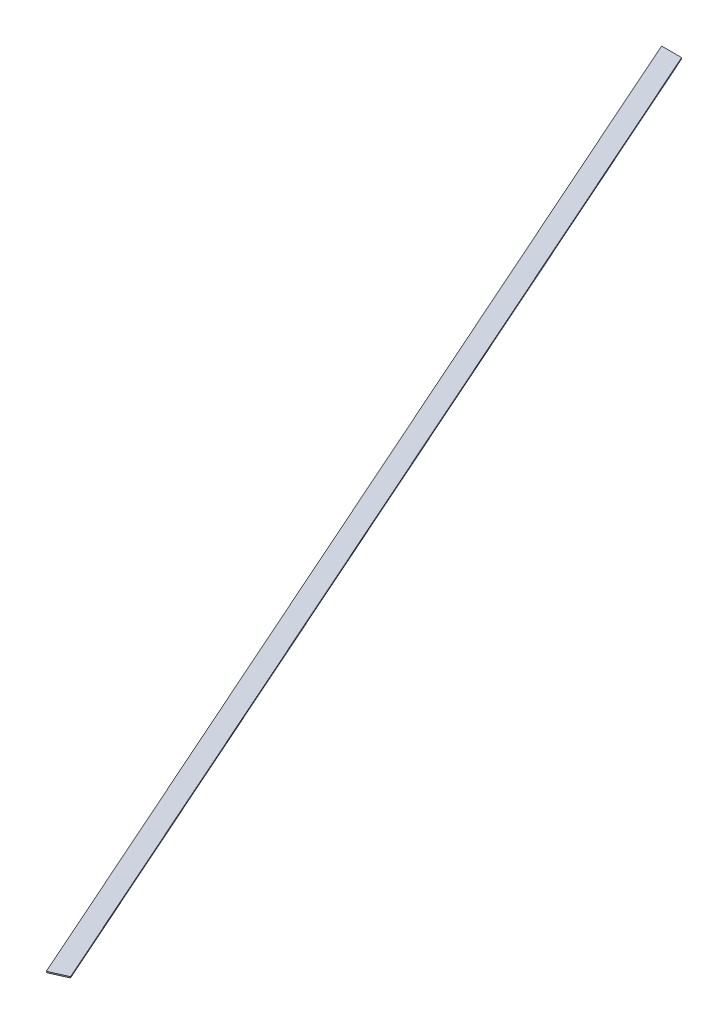
from build123d import *

# Parameters (mm, degrees)
BOSS_EXTRUDE1_DEPTH = 3.175
CUT_EXTRUDE1_DEPTH  = 4.175


with BuildPart() as part:
    # Sketch1 → Boss-Extrude1 (new body)
    with BuildSketch(Plane(origin=(0, 0, 0), x_dir=(1, 0, 0), z_dir=(0, 1, 0))):
        Polygon((27.803761474, 0), (-1804.223232834, 4114.8), (-1859.830755782, 4114.8), (-27.803761474, 0), align=None)
    extrude(amount=BOSS_EXTRUDE1_DEPTH)

    # Sketch2 → Cut-Extrude1 (cut, through all)
    with BuildSketch(Plane(origin=(0, 3.175, 0), x_dir=(1, 0, 0), z_dir=(0, 1, 0))):
        Polygon((27.803761474, 0), (-444.327999075, 1060.425296322), (-490.736108324, 1039.763074854), (-27.803761474, 0), align=None)
    extrude(amount=-CUT_EXTRUDE1_DEPTH, mode=Mode.SUBTRACT)


solid = part.part
